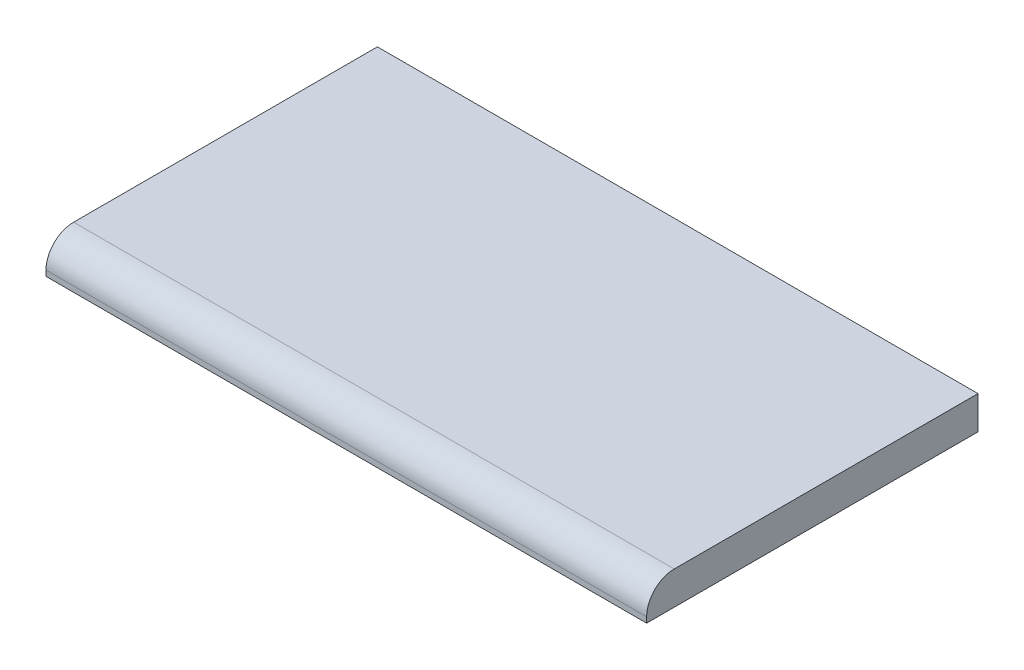
from build123d import *

# Parameters (mm, degrees)
SKETCH1_W           = 276.225
SKETCH1_H           = 152.4
SKETCH1_W_2         = 273.177
SKETCH1_H_2         = 149.352
BULK_EXTRUDE_DEPTH  = 15.24
FILLET1_R           = 12.7
SHELL_T             = -1.524
SKETCH2_R           = 1.651
BOSS_EXTRUDE3_DEPTH = 50.8


with BuildPart() as part:
    # Sketch1 → Bulk-Extrude (new body)
    with BuildSketch(Plane(origin=(0, 0, 0), x_dir=(1, 0, 0), z_dir=(0, 1, 0))):
        with Locations((136.5885, 74.676)):
            Rectangle(SKETCH1_W, SKETCH1_H)
        with Locations((136.5885, 74.676)):
            Rectangle(SKETCH1_W_2, SKETCH1_H_2, mode=Mode.SUBTRACT)
        with Locations((136.5885, 74.676)):
            Rectangle(SKETCH1_W_2, SKETCH1_H_2)
    extrude(amount=BULK_EXTRUDE_DEPTH)

    # Fillet1
    fillet1_edges = [part.edges().sort_by_distance(p)[0] for p in [
        (136.5885, 15.24, 1.524),
    ]]
    fillet(fillet1_edges, radius=FILLET1_R)

    # Shell
    shell_openings = [part.faces().sort_by_distance(p)[0] for p in [
        (136.5885, 0, -74.676),
    ]]
    offset(amount=SHELL_T, openings=shell_openings, kind=Kind.INTERSECTION)

    # Sketch2 → Boss-Extrude3 (add, symmetric)
    with BuildSketch(Plane(origin=(136.5885, 0, 0), x_dir=(0, 0, -1), z_dir=(1, 0, 0))):
        with BuildLine():
            Line((150.876, 3.175), (150.876, 0))
            ThreePointArc((150.876, 0), (156.29606403, -2.24506403), (154.051, 3.175))
            Line((154.051, 3.175), (150.876, 3.175))
        make_face()
        with Locations((154.051, 0)):
            Circle(SKETCH2_R, mode=Mode.SUBTRACT)
    extrude(amount=BOSS_EXTRUDE3_DEPTH, both=True)


solid = part.part
